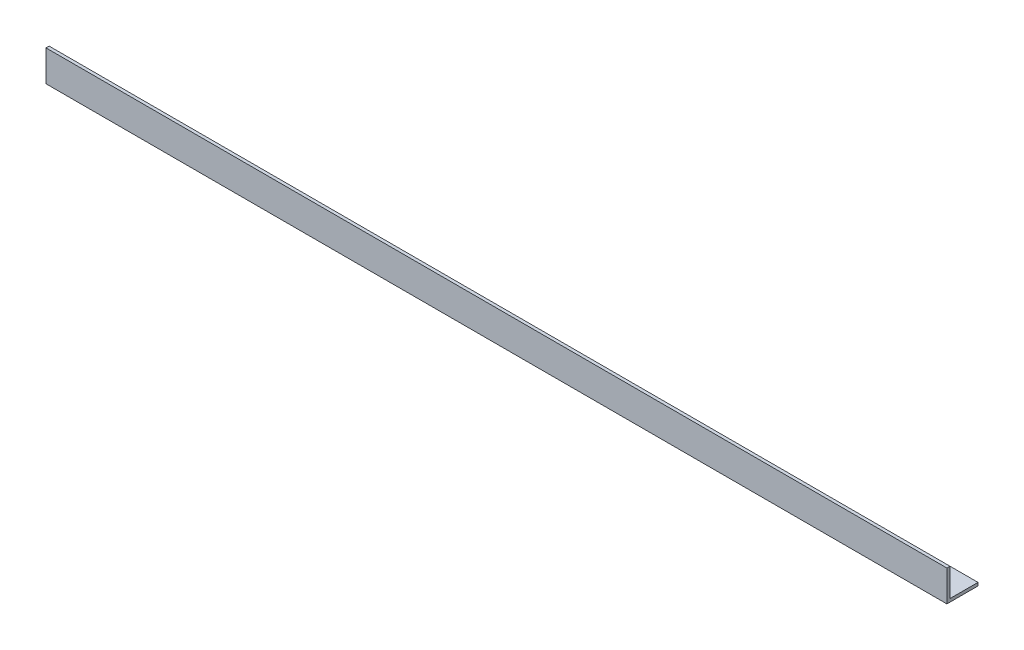
from build123d import *

# Parameters (mm, degrees)
EXTRUDE_1_DEPTH = 434.5


with BuildPart() as part:
    # Эскиз1 → Бобышка-Вытянуть1 (new body)
    with BuildSketch(Plane(origin=(0, 0, 0), x_dir=(0, 0, -1), z_dir=(1, 0, 0))):
        Polygon((0, 0), (0, 15), (1.5, 15), (1.5, 1.5), (15, 1.5), (15, 0), align=None)
    extrude(amount=EXTRUDE_1_DEPTH)


solid = part.part
